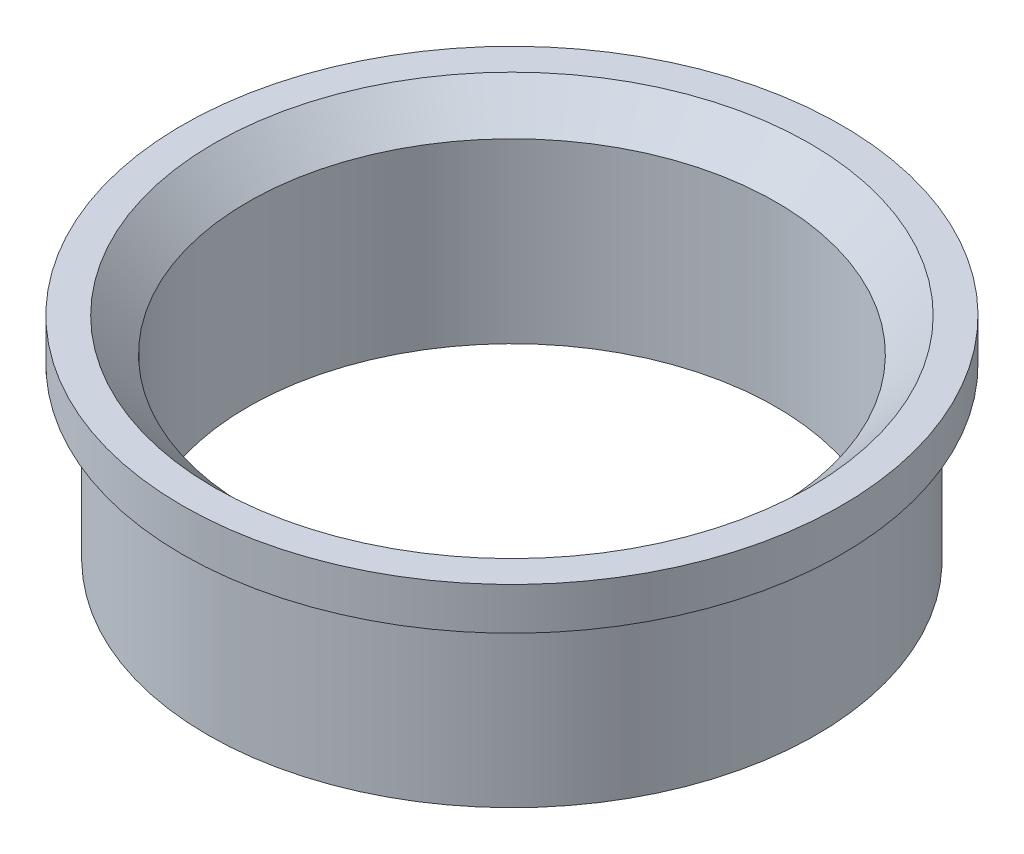
from build123d import *


with BuildPart() as part:
    # Sketch1 → Revolve1 (revolve)
    with BuildSketch(Plane(origin=(0, 0, 0), x_dir=(0, 0, -1), z_dir=(1, 0, 0))):
        Polygon((62.5, 0), (62.5, 42), (70.5, 50), (78, 50), (78, 40), (72, 40), (72, 0), align=None)
    revolve(axis=Axis((0, 75.298634812, 0), (0, -1, 0)))


solid = part.part
